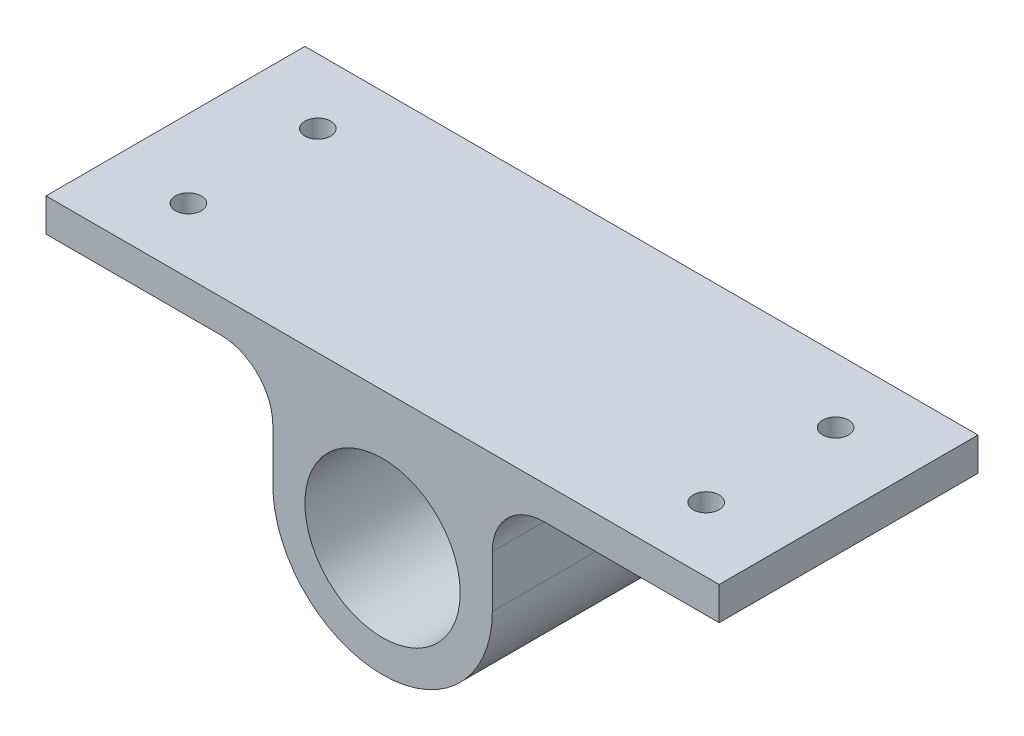
from build123d import *

# Parameters (mm, degrees)
SKETCH1_R           = 75
BOSS_EXTRUDE1_DEPTH = 250
CUT_EXTRUDE1_START  = 100
SKETCH2_R           = 12.5
CUT_EXTRUDE1_DEPTH  = 33


with BuildPart() as part:
    # Sketch1 → Boss-Extrude1 (new body)
    with BuildSketch(Plane.XY):
        with BuildLine():
            Line((-325, 132), (325, 132))
            Line((325, 132), (325, 100))
            Line((325, 100), (156, 100))
            ThreePointArc((156, 100), (120.644660941, 85.355339059), (106, 50))
            Line((106, 50), (106, 0))
            ThreePointArc((106, 0), (0, -106), (-106, 0))
            Line((-106, 0), (-106, 50))
            ThreePointArc((-106, 50), (-120.644660941, 85.355339059), (-156, 100))
            Line((-156, 100), (-325, 100))
            Line((-325, 100), (-325, 132))
        make_face()
        Circle(SKETCH1_R, mode=Mode.SUBTRACT)
    extrude(amount=BOSS_EXTRUDE1_DEPTH)

    # Sketch2 → Cut-Extrude1 (cut, through all)
    with BuildSketch(Plane(origin=(0, 0, 0), x_dir=(1, 0, 0), z_dir=(0, 1, 0)).offset(CUT_EXTRUDE1_START)):
        with Locations((-250, -62.5)):
            Circle(SKETCH2_R)
        with Locations((250, -62.5)):
            Circle(SKETCH2_R)
        with Locations((250, -187.5)):
            Circle(SKETCH2_R)
        with Locations((-250, -187.5)):
            Circle(SKETCH2_R)
    extrude(amount=CUT_EXTRUDE1_DEPTH, mode=Mode.SUBTRACT)


solid = part.part
